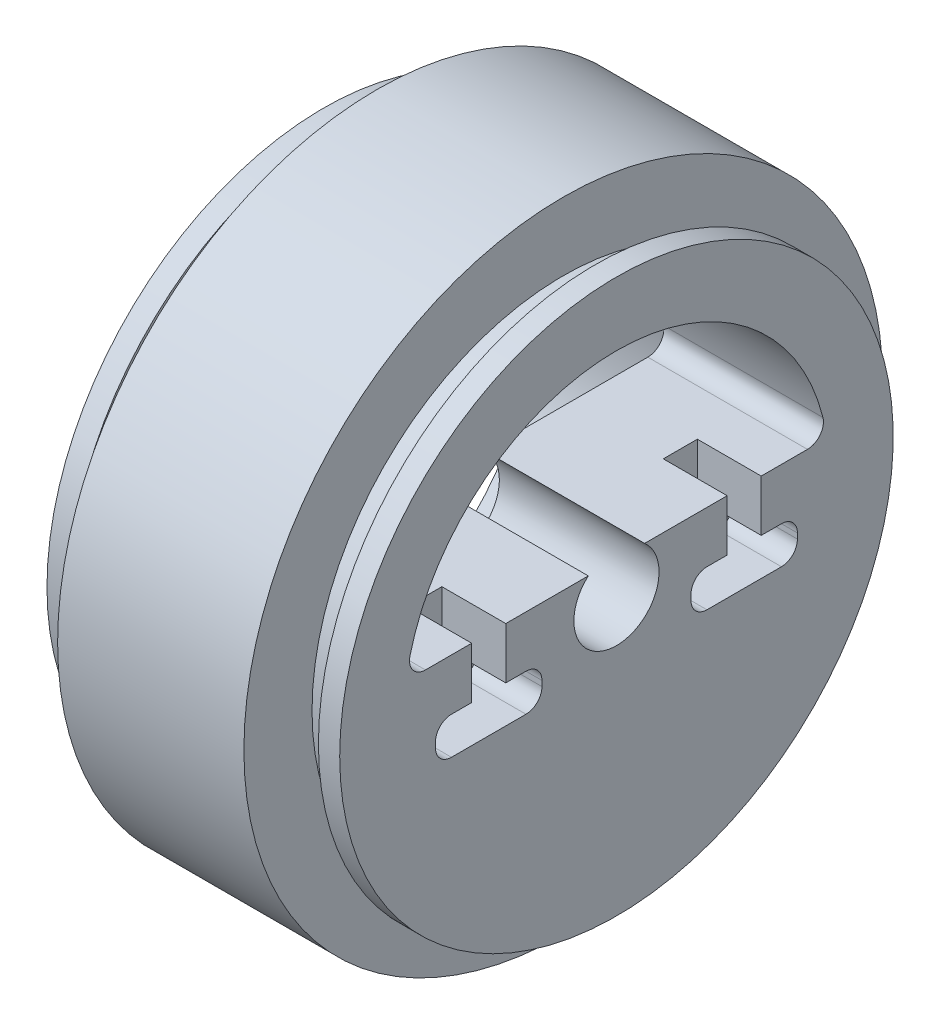
from build123d import *

# Parameters (mm, degrees)
EXTRUSION1_DEPTH = 28.5
EXTRUSION2_DEPTH = 6


with BuildPart() as part:
    # Esquisse1 → Révolution1 (revolve)
    with BuildSketch(Plane.XY):
        Polygon((-2.5, 20), (-2.5, 26), (-0.5, 26), (-0.5, 23.6), (2.5, 23.6), (2.5, 30), (20, 30), (20, 23.6), (23, 23.6), (23, 26), (25, 26), (25, 4), (10, 4), (10, 20), align=None)
    revolve(axis=Axis((10, 0, 0), (1, 0, 0)))

    # Esquisse2 → Extrusion1 (cut, through all)
    with BuildSketch(Plane(origin=(25, 0, 0), x_dir=(0, 0, -1), z_dir=(1, 0, 0))):
        with BuildLine():
            Line((17.944358445, 3), (-17.944358445, 3))
            ThreePointArc((-17.944358445, 3), (-19.127003214, 3.577312972), (-19.399306427, 4.864864865))
            ThreePointArc((-19.399306427, 4.864864865), (0, 20), (19.399306427, 4.864864865))
            ThreePointArc((19.399306427, 4.864864865), (19.127003214, 3.577312972), (17.944358445, 3))
        make_face()
    extrude(amount=-EXTRUSION1_DEPTH, mode=Mode.SUBTRACT)

    # Esquisse3 → Extrusion2 (cut)
    with BuildSketch(Plane(origin=(25, 0, 0), x_dir=(0, 0, -1), z_dir=(1, 0, 0))):
        with BuildLine():
            Line((-10.4, -1.829201479), (-10.4, 3.170798521))
            Line((-10.4, 3.170798521), (-13.6, 3.170798521))
            Line((-13.6, 3.170798521), (-13.6, -1.829201479))
            Line((-13.6, -1.829201479), (-15.5, -1.829201479))
            ThreePointArc((-15.5, -1.829201479), (-16.560660172, -2.268541307), (-17, -3.329201479))
            Line((-17, -3.329201479), (-17, -3.829201479))
            ThreePointArc((-17, -3.829201479), (-16.560660172, -4.889861651), (-15.5, -5.329201479))
            Line((-15.5, -5.329201479), (-8.5, -5.329201479))
            ThreePointArc((-8.5, -5.329201479), (-7.439339828, -4.889861651), (-7, -3.829201479))
            Line((-7, -3.829201479), (-7, -3.329201479))
            ThreePointArc((-7, -3.329201479), (-7.439339828, -2.268541307), (-8.5, -1.829201479))
            Line((-8.5, -1.829201479), (-10.4, -1.829201479))
        make_face()
        with BuildLine():
            Line((7, -3.329201479), (7, -3.829201479))
            ThreePointArc((7, -3.829201479), (7.439339828, -4.889861651), (8.5, -5.329201479))
            Line((8.5, -5.329201479), (15.5, -5.329201479))
            ThreePointArc((15.5, -5.329201479), (16.560660172, -4.889861651), (17, -3.829201479))
            Line((17, -3.829201479), (17, -3.329201479))
            ThreePointArc((17, -3.329201479), (16.560660172, -2.268541307), (15.5, -1.829201479))
            Line((15.5, -1.829201479), (13.6, -1.829201479))
            Line((13.6, -1.829201479), (13.6, 3.170798521))
            Line((13.6, 3.170798521), (10.4, 3.170798521))
            Line((10.4, 3.170798521), (10.4, -1.829201479))
            Line((10.4, -1.829201479), (8.5, -1.829201479))
            ThreePointArc((8.5, -1.829201479), (7.439339828, -2.268541307), (7, -3.329201479))
        make_face()
    extrude(amount=-EXTRUSION2_DEPTH, mode=Mode.SUBTRACT)


solid = part.part
